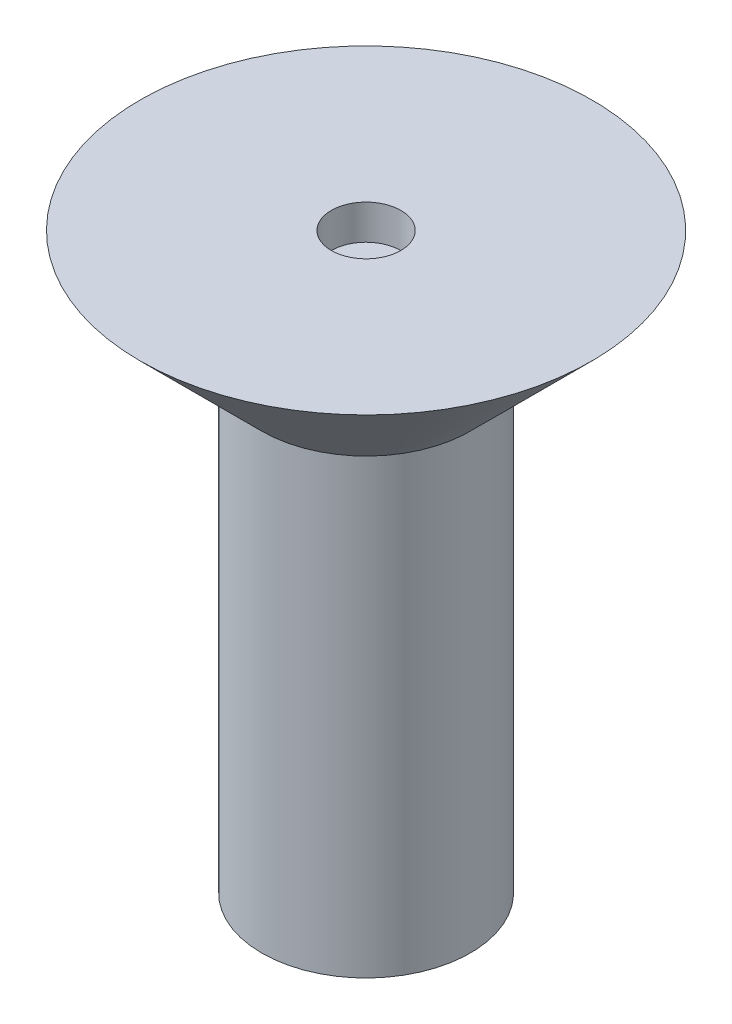
from build123d import *


with BuildPart() as part:
    # Sketch1 → Revolve1 (revolve)
    with BuildSketch(Plane.XY, mode=Mode.PRIVATE) as revolve1_sk:
        Polygon((0, -1.732050808), (0, 0), (-3, 0), align=None)
        Polygon((0, 0), (0, 15.5), (-1, 15.5), (-1, 16.5), (-6.5, 16.5), (-3, 13), (-3, 0), align=None)
    revolve(revolve1_sk.sketch.rotate(Axis((0, 81.864304429, 0), (0, -1, 0)), 270), axis=Axis((0, 81.864304429, 0), (0, -1, 0)))


solid = part.part
